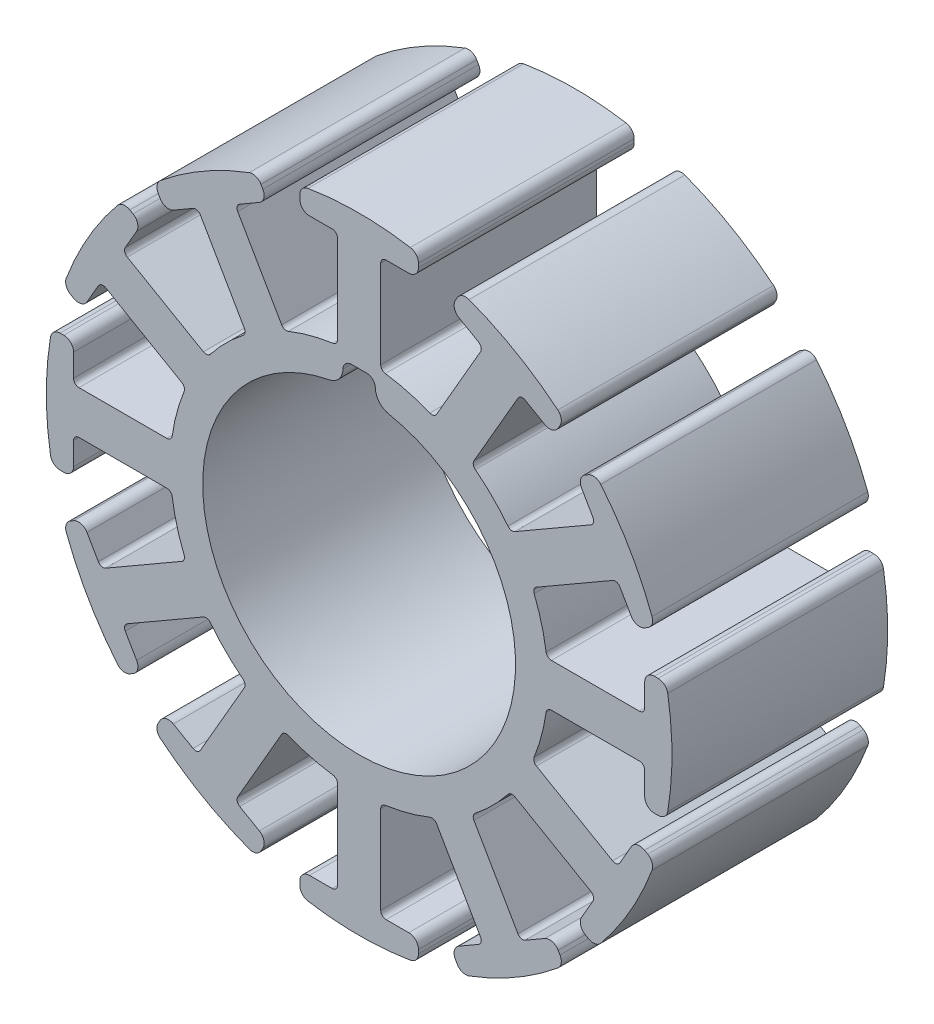
from build123d import *

# Parameters (mm, degrees)
SKETCH_1_R          = 14.5
EXTRUDE_1_DEPTH     = 20
FILLET_1_R          = 0.9
FILLET_2_R          = 0.9
FILLET_3_R          = 0.9
FILLET_4_R          = 0.9
FILLET_5_R          = 0.5
FILLET_6_R          = 0.5
SKETCH_3_W          = 3
SKETCH_3_H          = 4
CUT_EXTRUDE_1_DEPTH = 21
FILLET_7_R          = 1.55
FILLET_8_R          = 0.8


with BuildPart() as part:
    # ｽｹｯﾁ1 → ﾎﾞｽ - 押し出し1 (new body)
    with BuildSketch(Plane.XY):
        with BuildLine():
            Line((-2, 26.47367205), (-2, 17.385338651))
            ThreePointArc((-2, 17.385338651), (-4.529333289, 16.90370196), (-6.960618518, 16.056144925))
            Line((-6.960618518, 16.056144925), (-11.504785217, 23.926872527))
            Line((-11.504785217, 23.926872527), (-8.473696304, 25.676872527))
            Line((-8.473696304, 25.676872527), (-9.473696304, 27.408923334))
            ThreePointArc((-9.473696304, 27.408923334), (-14.5, 25.11473671), (-18.999975746, 21.908923334))
            Line((-18.999975746, 21.908923334), (-17.999975746, 20.176872527))
            Line((-17.999975746, 20.176872527), (-14.968886832, 21.926872527))
            Line((-14.968886832, 21.926872527), (-10.424720133, 14.056144925))
            ThreePointArc((-10.424720133, 14.056144925), (-12.374368671, 12.374368671), (-14.056144925, 10.424720133))
            Line((-14.056144925, 10.424720133), (-21.926872527, 14.968886832))
            Line((-21.926872527, 14.968886832), (-20.176872527, 17.999975746))
            Line((-20.176872527, 17.999975746), (-21.908923334, 18.999975746))
            ThreePointArc((-21.908923334, 18.999975746), (-25.11473671, 14.5), (-27.408923334, 9.473696304))
            Line((-27.408923334, 9.473696304), (-25.676872527, 8.473696304))
            Line((-25.676872527, 8.473696304), (-23.926872527, 11.504785217))
            Line((-23.926872527, 11.504785217), (-16.056144925, 6.960618518))
            ThreePointArc((-16.056144925, 6.960618518), (-16.90370196, 4.529333289), (-17.385338651, 2))
            Line((-17.385338651, 2), (-26.47367205, 2))
            Line((-26.47367205, 2), (-26.47367205, 5.5))
            Line((-26.47367205, 5.5), (-28.47367205, 5.5))
            ThreePointArc((-28.47367205, 5.5), (-29, 0), (-28.47367205, -5.5))
            Line((-28.47367205, -5.5), (-26.47367205, -5.5))
            Line((-26.47367205, -5.5), (-26.47367205, -2))
            Line((-26.47367205, -2), (-17.385338651, -2))
            ThreePointArc((-17.385338651, -2), (-16.90370196, -4.529333289), (-16.056144925, -6.960618518))
            Line((-16.056144925, -6.960618518), (-23.926872527, -11.504785217))
            Line((-23.926872527, -11.504785217), (-25.676872527, -8.473696304))
            Line((-25.676872527, -8.473696304), (-27.408923334, -9.473696304))
            ThreePointArc((-27.408923334, -9.473696304), (-25.11473671, -14.5), (-21.908923334, -18.999975746))
            Line((-21.908923334, -18.999975746), (-20.176872527, -17.999975746))
            Line((-20.176872527, -17.999975746), (-21.926872527, -14.968886832))
            Line((-21.926872527, -14.968886832), (-14.056144925, -10.424720133))
            ThreePointArc((-14.056144925, -10.424720133), (-12.374368671, -12.374368671), (-10.424720133, -14.056144925))
            Line((-10.424720133, -14.056144925), (-14.968886832, -21.926872527))
            Line((-14.968886832, -21.926872527), (-17.999975746, -20.176872527))
            Line((-17.999975746, -20.176872527), (-18.999975746, -21.908923334))
            ThreePointArc((-18.999975746, -21.908923334), (-14.5, -25.11473671), (-9.473696304, -27.408923334))
            Line((-9.473696304, -27.408923334), (-8.473696304, -25.676872527))
            Line((-8.473696304, -25.676872527), (-11.504785217, -23.926872527))
            Line((-11.504785217, -23.926872527), (-6.960618518, -16.056144925))
            ThreePointArc((-6.960618518, -16.056144925), (-4.529333289, -16.90370196), (-2, -17.385338651))
            Line((-2, -17.385338651), (-2, -26.47367205))
            Line((-2, -26.47367205), (-5.5, -26.47367205))
            Line((-5.5, -26.47367205), (-5.5, -28.47367205))
            ThreePointArc((-5.5, -28.47367205), (0, -29), (5.5, -28.47367205))
            Line((5.5, -28.47367205), (5.5, -26.47367205))
            Line((5.5, -26.47367205), (2, -26.47367205))
            Line((2, -26.47367205), (2, -17.385338651))
            ThreePointArc((2, -17.385338651), (4.529333289, -16.90370196), (6.960618518, -16.056144925))
            Line((6.960618518, -16.056144925), (11.504785217, -23.926872527))
            Line((11.504785217, -23.926872527), (8.473696304, -25.676872527))
            Line((8.473696304, -25.676872527), (9.473696304, -27.408923334))
            ThreePointArc((9.473696304, -27.408923334), (14.5, -25.11473671), (18.999975746, -21.908923334))
            Line((18.999975746, -21.908923334), (17.999975746, -20.176872527))
            Line((17.999975746, -20.176872527), (14.968886832, -21.926872527))
            Line((14.968886832, -21.926872527), (10.424720133, -14.056144925))
            ThreePointArc((10.424720133, -14.056144925), (12.374368671, -12.374368671), (14.056144925, -10.424720133))
            Line((14.056144925, -10.424720133), (21.926872527, -14.968886832))
            Line((21.926872527, -14.968886832), (20.176872527, -17.999975746))
            Line((20.176872527, -17.999975746), (21.908923334, -18.999975746))
            ThreePointArc((21.908923334, -18.999975746), (25.11473671, -14.5), (27.408923334, -9.473696304))
            Line((27.408923334, -9.473696304), (25.676872527, -8.473696304))
            Line((25.676872527, -8.473696304), (23.926872527, -11.504785217))
            Line((23.926872527, -11.504785217), (16.056144925, -6.960618518))
            ThreePointArc((16.056144925, -6.960618518), (16.90370196, -4.529333289), (17.385338651, -2))
            Line((17.385338651, -2), (26.47367205, -2))
            Line((26.47367205, -2), (26.47367205, -5.5))
            Line((26.47367205, -5.5), (28.47367205, -5.5))
            ThreePointArc((28.47367205, -5.5), (29, 0), (28.47367205, 5.5))
            Line((28.47367205, 5.5), (26.47367205, 5.5))
            Line((26.47367205, 5.5), (26.47367205, 2))
            Line((26.47367205, 2), (17.385338651, 2))
            ThreePointArc((17.385338651, 2), (16.90370196, 4.529333289), (16.056144925, 6.960618518))
            Line((16.056144925, 6.960618518), (23.926872527, 11.504785217))
            Line((23.926872527, 11.504785217), (25.676872527, 8.473696304))
            Line((25.676872527, 8.473696304), (27.408923334, 9.473696304))
            ThreePointArc((27.408923334, 9.473696304), (25.11473671, 14.5), (21.908923334, 18.999975746))
            Line((21.908923334, 18.999975746), (20.176872527, 17.999975746))
            Line((20.176872527, 17.999975746), (21.926872527, 14.968886832))
            Line((21.926872527, 14.968886832), (14.056144925, 10.424720133))
            ThreePointArc((14.056144925, 10.424720133), (12.374368671, 12.374368671), (10.424720133, 14.056144925))
            Line((10.424720133, 14.056144925), (14.968886832, 21.926872527))
            Line((14.968886832, 21.926872527), (17.999975746, 20.176872527))
            Line((17.999975746, 20.176872527), (18.999975746, 21.908923334))
            ThreePointArc((18.999975746, 21.908923334), (14.5, 25.11473671), (9.473696304, 27.408923334))
            Line((9.473696304, 27.408923334), (8.473696304, 25.676872527))
            Line((8.473696304, 25.676872527), (11.504785217, 23.926872527))
            Line((11.504785217, 23.926872527), (6.960618518, 16.056144925))
            ThreePointArc((6.960618518, 16.056144925), (4.529333289, 16.90370196), (2, 17.385338651))
            Line((2, 17.385338651), (2, 26.47367205))
            Line((2, 26.47367205), (5.5, 26.47367205))
            Line((5.5, 26.47367205), (5.5, 28.47367205))
            ThreePointArc((5.5, 28.47367205), (0, 29), (-5.5, 28.47367205))
            Line((-5.5, 28.47367205), (-5.5, 26.47367205))
            Line((-5.5, 26.47367205), (-2, 26.47367205))
        make_face()
        Circle(SKETCH_1_R, mode=Mode.SUBTRACT)
    extrude(amount=EXTRUDE_1_DEPTH)

    # ﾌｨﾚｯﾄ1
    fillet_1_edges = [part.edges().sort_by_distance(p)[0] for p in [
        (-17.999975746, 20.176872527, 10),
        (-18.999975746, 21.908923334, 10),
        (-9.473696304, 27.408923334, 10),
        (-8.473696304, 25.676872527, 10),
    ]]
    fillet(fillet_1_edges, radius=FILLET_1_R)

    # ﾌｨﾚｯﾄ2
    fillet_2_edges = [part.edges().sort_by_distance(p)[0] for p in [
        (5.5, 28.47367205, 10),
        (5.5, 26.47367205, 10),
        (8.473696304, 25.676872527, 10),
        (9.473696304, 27.408923334, 10),
        (18.999975746, 21.908923334, 10),
        (17.999975746, 20.176872527, 10),
        (20.176872527, 17.999975746, 10),
        (21.908923334, 18.999975746, 10),
        (27.408923334, 9.473696304, 10),
        (25.676872527, 8.473696304, 10),
        (-5.5, 26.47367205, 10),
        (-5.5, 28.47367205, 10),
    ]]
    fillet(fillet_2_edges, radius=FILLET_2_R)

    # ﾌｨﾚｯﾄ3
    fillet_3_edges = [part.edges().sort_by_distance(p)[0] for p in [
        (26.47367205, 5.5, 10),
        (28.47367205, 5.5, 10),
        (28.47367205, -5.5, 10),
        (26.47367205, -5.5, 10),
        (25.676872527, -8.473696304, 10),
        (27.408923334, -9.473696304, 10),
        (21.908923334, -18.999975746, 10),
        (20.176872527, -17.999975746, 10),
    ]]
    fillet(fillet_3_edges, radius=FILLET_3_R)

    # ﾌｨﾚｯﾄ4
    fillet_4_edges = [part.edges().sort_by_distance(p)[0] for p in [
        (17.999975746, -20.176872527, 10),
        (18.999975746, -21.908923334, 10),
        (9.473696304, -27.408923334, 10),
        (8.473696304, -25.676872527, 10),
        (5.5, -26.47367205, 10),
        (5.5, -28.47367205, 10),
        (-5.5, -28.47367205, 10),
        (-5.5, -26.47367205, 10),
        (-8.473696304, -25.676872527, 10),
        (-9.473696304, -27.408923334, 10),
        (-18.999975746, -21.908923334, 10),
        (-17.999975746, -20.176872527, 10),
        (-20.176872527, -17.999975746, 10),
        (-21.908923334, -18.999975746, 10),
        (-27.408923334, -9.473696304, 10),
        (-25.676872527, -8.473696304, 10),
        (-26.47367205, -5.5, 10),
        (-28.47367205, -5.5, 10),
        (-28.47367205, 5.5, 10),
        (-26.47367205, 5.5, 10),
        (-25.676872527, 8.473696304, 10),
        (-27.408923334, 9.473696304, 10),
        (-21.908923334, 18.999975746, 10),
        (-20.176872527, 17.999975746, 10),
    ]]
    fillet(fillet_4_edges, radius=FILLET_4_R)

    # ﾌｨﾚｯﾄ5
    fillet_5_edges = [part.edges().sort_by_distance(p)[0] for p in [
        (23.926872527, 11.504785217, 10),
        (16.056144925, 6.960618518, 10),
        (17.385338651, 2, 10),
        (26.47367205, 2, 10),
        (26.47367205, -2, 10),
        (17.385338651, -2, 10),
        (16.056144925, -6.960618518, 10),
        (23.926872527, -11.504785217, 10),
        (21.926872527, -14.968886832, 10),
        (14.056144925, -10.424720133, 10),
        (10.424720133, -14.056144925, 10),
        (14.968886832, -21.926872527, 10),
        (11.504785217, -23.926872527, 10),
        (6.960618518, -16.056144925, 10),
        (2, -17.385338651, 10),
        (2, -26.47367205, 10),
        (-2, -26.47367205, 10),
        (-2, -17.385338651, 10),
        (-6.960618518, -16.056144925, 10),
        (-11.504785217, -23.926872527, 10),
        (-14.968886832, -21.926872527, 10),
        (-10.424720133, -14.056144925, 10),
        (-14.056144925, -10.424720133, 10),
        (-21.926872527, -14.968886832, 10),
        (-23.926872527, -11.504785217, 10),
        (-16.056144925, -6.960618518, 10),
    ]]
    fillet(fillet_5_edges, radius=FILLET_5_R)

    # ﾌｨﾚｯﾄ6
    fillet_6_edges = [part.edges().sort_by_distance(p)[0] for p in [
        (2, 26.47367205, 10),
        (2, 17.385338651, 10),
        (6.960618518, 16.056144925, 10),
        (11.504785217, 23.926872527, 10),
        (14.968886832, 21.926872527, 10),
        (10.424720133, 14.056144925, 10),
        (14.056144925, 10.424720133, 10),
        (21.926872527, 14.968886832, 10),
        (-17.385338651, -2, 10),
        (-26.47367205, -2, 10),
        (-26.47367205, 2, 10),
        (-17.385338651, 2, 10),
        (-16.056144925, 6.960618518, 10),
        (-23.926872527, 11.504785217, 10),
        (-21.926872527, 14.968886832, 10),
        (-14.056144925, 10.424720133, 10),
        (-10.424720133, 14.056144925, 10),
        (-14.968886832, 21.926872527, 10),
        (-11.504785217, 23.926872527, 10),
        (-6.960618518, 16.056144925, 10),
        (-2, 17.385338651, 10),
        (-2, 26.47367205, 10),
    ]]
    fillet(fillet_6_edges, radius=FILLET_6_R)

    # ｽｹｯﾁ3 → ｶｯﾄ - 押し出し1 (cut, through all)
    with BuildSketch(Plane.XY.offset(20)):
        with Locations((0, 14.5)):
            Rectangle(SKETCH_3_W, SKETCH_3_H)
    extrude(amount=-CUT_EXTRUDE_1_DEPTH, mode=Mode.SUBTRACT)

    # ﾌｨﾚｯﾄ7
    fillet_7_edges = [part.edges().sort_by_distance(p)[0] for p in [
        (-1.5, 14.422205102, 10),
        (1.5, 14.422205102, 10),
    ]]
    fillet(fillet_7_edges, radius=FILLET_7_R)

    # ﾌｨﾚｯﾄ8
    fillet_8_edges = [part.edges().sort_by_distance(p)[0] for p in [
        (1.5, 16.5, 10),
        (-1.5, 16.5, 10),
    ]]
    fillet(fillet_8_edges, radius=FILLET_8_R)


solid = part.part
